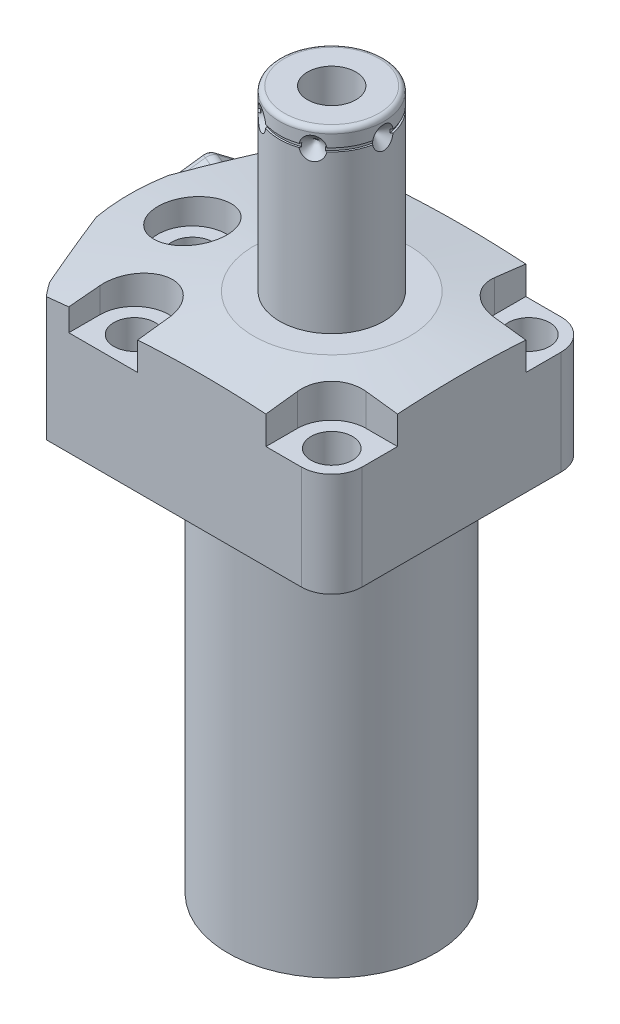
from build123d import *

# Parameters (mm, degrees)
CUT_EXTRUDE1_DEPTH       = 32.9946
CUT_EXTRUDE2_DEPTH       = 30.1498
CUT_EXTRUDE3_DEPTH       = 32.9946
FILLET1_R                = 6.477
CUT_EXTRUDE4_DEPTH       = 8.001
SKETCH11_R               = 2.7432
EXTRUDE1_DEPTH           = 2.9972
CUT_EXTRUDE5_DEPTH       = 1.27
CHAMFER1_SIZE            = 0.254
CHAMFER1_OF_MIRROR2_SIZE = 0.254
SKETCH16_R               = 1
SKETCH19_R               = 8.5
EXTRUDE3_DEPTH           = 1
SKETCH22_W               = 0.381
SKETCH22_H               = 0.762
HOLE1_AT_2_COUNT         = 2
HOLE1_AT_2_PITCH         = 54.877785999
HOLE1_AT_3_COUNT         = 2
HOLE1_AT_3_PITCH         = 54.877785999
HOLE1_AT_4_COUNT         = 2
HOLE1_AT_4_PITCH         = 22.73112685
HOLE1_AT_5_COUNT         = 2
HOLE1_AT_5_PITCH         = 22.73112685
SKETCH25_R               = 11.3665
CUT_EXTRUDE7_DEPTH       = 1.524
EXTRUDE4_DEPTH           = 6.87
FILLET2_R                = 2
CIRPATTERN1_COUNT        = 6


with BuildPart() as part:
    # S2D0002 → Revolve1 (revolve)
    with BuildSketch(Plane.XY, mode=Mode.PRIVATE) as revolve1_sk:
        Polygon((-43.18, 0), (-43.18, 30.1498), (0, 30.1498), (0, -80.9752), (-22.098, -80.9752), (-22.098, 0), align=None)
    revolve(revolve1_sk.sketch.rotate(Axis((0, -3.4925, 0), (0, 1, 0)), 270), axis=Axis((0, -3.4925, 0), (0, 1, 0)))  # turned: the seam where the file's is

    # S2D0001 → Cut-Extrude1 (cut)
    with BuildSketch(Plane.XZ):
        with BuildLine():
            Line((-33.136049915, -27.686), (33.136049915, -27.686))
            ThreePointArc((33.136049915, -27.686), (0, -43.18), (-33.136049915, -27.686))
        make_face()
        with BuildLine():
            Line((33.136049915, 27.686), (-33.136049915, 27.686))
            ThreePointArc((-33.136049915, 27.686), (0, 43.18), (33.136049915, 27.686))
        make_face()
    extrude(amount=-CUT_EXTRUDE1_DEPTH, mode=Mode.SUBTRACT)

    # Sketch3 → Cut-Extrude2 (cut)
    with BuildSketch(Plane(origin=(0, 30.1498, 0), x_dir=(-1, 0, 0), z_dir=(0, -1, 0))):
        with BuildLine():
            Line((21.331674578, 58.746997027), (45.665477495, 0))
            Line((45.665477495, 0), (21.331674578, -58.746997027))
            ThreePointArc((21.331674578, -58.746997027), (62.5, 0), (21.331674578, 58.746997027))
        make_face()
    extrude(amount=CUT_EXTRUDE2_DEPTH, mode=Mode.SUBTRACT)

    # Sketch4 → Cut-Extrude3 (cut)
    with BuildSketch(Plane.XZ):
        with BuildLine():
            Line((27.686, -33.136049915), (27.686, 33.136049915))
            ThreePointArc((27.686, 33.136049915), (43.18, 0), (27.686, -33.136049915))
        make_face()
    extrude(amount=-CUT_EXTRUDE3_DEPTH, mode=Mode.SUBTRACT)

    # Fillet1
    fillet1_edges = [part.edges().sort_by_distance(p)[0] for p in [
        (27.686, 15.0749, 27.686),
        (27.686, 15.0749, -27.686),
    ]]
    fillet(fillet1_edges, radius=FILLET1_R)

    # Sketch5 → Cut-Extrude4 (cut)
    with BuildSketch(Plane(origin=(0, 30.1498, 0), x_dir=(-1, 0, 0), z_dir=(0, 1, 0))):
        with BuildLine():
            Line((-27.686, -13.6652), (-27.686, -27.686))
            Line((-27.686, -27.686), (-13.6652, -27.686))
            Line((-13.6652, -27.686), (-13.6652, -21.0058))
            ThreePointArc((-13.6652, -21.0058), (-15.815211962, -15.815211962), (-21.0058, -13.6652))
            Line((-21.0058, -13.6652), (-27.686, -13.6652))
        make_face()
        with BuildLine():
            Line((-13.6652, 21.0058), (-13.6652, 27.686))
            Line((-13.6652, 27.686), (-27.686, 27.686))
            Line((-27.686, 27.686), (-27.686, 13.6652))
            Line((-27.686, 13.6652), (-21.0058, 13.6652))
            ThreePointArc((-21.0058, 13.6652), (-15.815211962, 15.815211962), (-13.6652, 21.0058))
        make_face()
        with BuildLine():
            Line((13.6652, 27.686), (28.3464, 27.686))
            Line((28.3464, 27.686), (28.3464, 21.0058))
            ThreePointArc((28.3464, 21.0058), (21.0058, 13.6652), (13.6652, 21.0058))
            Line((13.6652, 21.0058), (13.6652, 27.686))
        make_face()
        with BuildLine():
            Line((13.6652, -27.686), (13.6652, -21.0058))
            ThreePointArc((13.6652, -21.0058), (21.0058, -13.6652), (28.3464, -21.0058))
            Line((28.3464, -21.0058), (28.3464, -27.686))
            Line((28.3464, -27.686), (13.6652, -27.686))
        make_face()
    extrude(amount=-CUT_EXTRUDE4_DEPTH, mode=Mode.SUBTRACT)

    # S2D0003 → Cut-Revolve1 (revolve, cut)
    with BuildSketch(Plane.XY, mode=Mode.PRIVATE) as cut_revolve1_sk:
        Polygon((-16.637, 30.1498), (-86.637, 20.311941571), (-86.637, 30.1498), align=None)
    revolve(cut_revolve1_sk.sketch.rotate(Axis((0, 12.958028823, 0), (0, 1, 0)), 270), axis=Axis((0, 12.958028823, 0), (0, 1, 0)), mode=Mode.SUBTRACT)  # turned: the seam where the file's is

    # Sketch7 → Cut-Revolve2 (revolve, cut)
    with BuildSketch(Plane.XZ.offset(-14.5034)):
        Polygon((-41.173297543, -10.181347778), (-42.857104646, -6.116277835), (-43.091770047, -6.213479427), (-38.977923149, -16.145184401), (-25.648928357, -10.624133986), (-27.923445606, -5.132963597), (-40.549917486, -10.363019494), (-41.04563442, -10.157686817), align=None)
    cut_revolve2 = revolve(axis=Axis((0, 14.5034, 0), (0.923879533, 0, 0.382683432)), mode=Mode.SUBTRACT)

    # Sketch9 → Cut-Revolve4 (revolve, cut)
    with BuildSketch(Plane.XY.offset(-11.8364), mode=Mode.PRIVATE) as cut_revolve4_sk:
        Polygon((-31.8262, 1.5), (-33.575, 1.5), (-33.575, 0), (-28.575, 0), (-28.575, 12.0664), (-29.8196, 12.0664), (-29.8196, 4.4972), (-31.8262, 4.4972), align=None)
    cut_revolve4 = revolve(cut_revolve4_sk.sketch.rotate(Axis((-28.575, -17.893386483, -11.8364), (0, 1, 0)), 180), axis=Axis((-28.575, -17.893386483, -11.8364), (0, 1, 0)), mode=Mode.SUBTRACT)  # turned: the seam where the file's is

    # Sketch11 → Extrude1 (add)
    with BuildSketch(Plane.XZ.offset(-4.4972)):
        with Locations(Location((-28.575, -11.8364, 0), (0, 0, 270))):  # turned: the seam where the file's is
            Circle(SKETCH11_R)
    extrude1 = extrude(amount=EXTRUDE1_DEPTH)

    # Sketch12 → Cut-Extrude5 (cut)
    with BuildSketch(Plane.XZ.offset(-1.5)):
        Polygon((-27.3304, -12.554970145), (-27.3304, -11.117829855), (-28.575, -10.39925971), (-29.8196, -11.117829855), (-29.8196, -12.554970145), (-28.575, -13.27354029), align=None)
    cut_extrude5 = extrude(amount=-CUT_EXTRUDE5_DEPTH, mode=Mode.SUBTRACT)

    # Chamfer1
    chamfer1_edges = [part.edges().sort_by_distance(p)[0] for p in [
        (-28.575, 1.5, -9.0932),
    ]]
    chamfer(chamfer1_edges, length=CHAMFER1_SIZE)

    # Mirror2: Cut-Revolve2, Cut-Revolve4, Extrude1, Cut-Extrude5 across plane
    add(cut_revolve2.mirror(Plane.XY), mode=Mode.SUBTRACT)
    add(cut_revolve4.mirror(Plane.XY), mode=Mode.SUBTRACT)
    add(extrude1.mirror(Plane.XY))
    add(cut_extrude5.mirror(Plane.XY), mode=Mode.SUBTRACT)

    # Chamfer1 of Mirror2
    chamfer1_of_mirror2_edges = [part.edges().sort_by_distance(p)[0] for p in [
        (-28.575, 1.5, 9.0932),
    ]]
    chamfer(chamfer1_of_mirror2_edges, length=CHAMFER1_OF_MIRROR2_SIZE)

    # Sketch17 → Revolve4 (revolve)
    with BuildSketch(Plane(origin=(0, 0, 0), x_dir=(0, 0, -1), z_dir=(1, 0, 0)), mode=Mode.PRIVATE) as revolve4_sk:
        with BuildLine():
            Line((0, 30.1498), (-11.1125, 30.1498))
            Line((-11.1125, 30.1498), (-11.1125, 67.018))
            ThreePointArc((-11.1125, 67.018), (-10.81492049, 67.73642049), (-10.0965, 68.034))
            Line((-10.0965, 68.034), (0, 68.034))
            Line((0, 68.034), (0, 30.1498))
        make_face()
    revolve(revolve4_sk.sketch.rotate(Axis((0, 24.99613, 0), (0, 1, 0)), 180), axis=Axis((0, 24.99613, 0), (0, 1, 0)))  # turned: the seam where the file's is

    # Sketch18 → Cut-Revolve7 (revolve, cut)
    with BuildSketch(Plane.XY, mode=Mode.PRIVATE) as cut_revolve7_sk:
        Polygon((5.1562, 68.034), (5.1562, 51.016), (0, 47.917842476), (0, 68.034), align=None)
    revolve(cut_revolve7_sk.sketch.rotate(Axis((0, -20.475979697, 0), (0, 1, 0)), 90), axis=Axis((0, -20.475979697, 0), (0, 1, 0)), mode=Mode.SUBTRACT)  # turned: the seam where the file's is

    # Sketch19 → Extrude3 (add)
    with BuildSketch(Plane(origin=(-52.256800889, 0, 16.576596317), x_dir=(-0.382683432, 0, 0.923879533), z_dir=(-0.923879533, 0, -0.382683432))):
        with Locations((-35.312589984, 14.5034)):
            Circle(SKETCH19_R)
    extrude(amount=EXTRUDE3_DEPTH)

    # Sketch20 → Cut-Revolve8 (revolve, cut)
    with BuildSketch(Plane.XY, mode=Mode.PRIVATE) as cut_revolve8_sk:
        Polygon((-11.1125, 61.6586), (-11.1125, 64.0716), (-8.6995, 64.0716), align=None)
    cut_revolve8 = revolve(cut_revolve8_sk.sketch.rotate(Axis((0, 64.0716, 0), (1, 0, 0)), 270), axis=Axis((0, 64.0716, 0), (1, 0, 0)), mode=Mode.SUBTRACT)  # turned: the seam where the file's is

    # Sketch22 → Cut-Revolve6 (revolve, cut)
    with BuildSketch(Plane(origin=(0, 0, 0), x_dir=(0, 0, -1), z_dir=(1, 0, 0))):
        with Locations((10.922, 64.072)):
            Rectangle(SKETCH22_W, SKETCH22_H)
    revolve(axis=Axis((0, 41.8979, 0), (0, 1, 0)), mode=Mode.SUBTRACT)

    # Sketch23 → Hole1 (revolve, cut)
    with BuildSketch(Plane(origin=(-29.6926, 30.1498, 0), x_dir=(0, 0, 1), z_dir=(1, 0, 0))):
        Polygon((0, 0), (0, 30.1498), (4.4196, 30.1498), (4.4196, 8.001), (7.3406, 8.001), (7.3406, 0), align=None)
    hole1 = revolve(axis=Axis((-29.6926, -79.8502, 0), (0, 1, 0)), mode=Mode.SUBTRACT)

    # Hole1 at 2: Hole1 ×2
    with Locations(*[Vector(0.923841935, 0, 0.382774188) * (i * HOLE1_AT_2_PITCH) for i in range(1, HOLE1_AT_2_COUNT)]):
        add(hole1, mode=Mode.SUBTRACT)

    # Hole1 at 3: Hole1 ×2
    with Locations(*[Vector(0.923841935, 0, -0.382774188) * (i * HOLE1_AT_3_PITCH) for i in range(1, HOLE1_AT_3_COUNT)]):
        add(hole1, mode=Mode.SUBTRACT)

    # Hole1 at 4: Hole1 ×2
    with Locations(*[Vector(0.382154394, 0, 0.92409849) * (i * HOLE1_AT_4_PITCH) for i in range(1, HOLE1_AT_4_COUNT)]):
        add(hole1, mode=Mode.SUBTRACT)

    # Hole1 at 5: Hole1 ×2
    with Locations(*[Vector(0.382154394, 0, -0.92409849) * (i * HOLE1_AT_5_PITCH) for i in range(1, HOLE1_AT_5_COUNT)]):
        add(hole1, mode=Mode.SUBTRACT)

    # Sketch25 → Cut-Extrude7 (cut)
    with BuildSketch(Plane.XZ.offset(80.9752)):
        with Locations(Location((0, 0, 0), (0, 0, 270))):  # turned: the seam where the file's is
            Circle(SKETCH25_R)
    extrude(amount=-CUT_EXTRUDE7_DEPTH, mode=Mode.SUBTRACT)

    # Sketch27 → Extrude4 (add)
    with BuildSketch(Plane(origin=(-39.66713728, 0, -16.430666242), x_dir=(-0.382683432, 0, 0.923879533), z_dir=(-0.923879533, 0, -0.382683432))):
        Polygon((8.399828748, 19.580427707), (-0.196920596, 24.316378937), (-8.596749344, 19.239351229), (-8.399828748, 9.426372293), (0.196920596, 4.690421063), (8.596749344, 9.767448771), align=None)
    extrude(amount=EXTRUDE4_DEPTH)

    # Fillet2
    fillet2_edges = [part.edges().sort_by_distance(p)[0] for p in [
        (-46.130497021, 9.767448771, -9.802823067),
        (-46.055138771, 19.580427707, -9.984753975),
        (-42.765305225, 24.316378937, -17.927114741),
        (-39.550829928, 19.239351229, -25.687544597),
        (-39.626188178, 9.426372293, -25.505613689),
        (-42.916021724, 4.690421063, -17.563252924),
        (-49.26634409, 14.673938239, -11.208306111),
        (-47.583748192, 21.948403322, -15.270451948),
        (-44.331593771, 21.777865083, -23.121847259),
        (-42.762035247, 14.332861761, -26.911096733),
        (-44.444631145, 7.058396678, -22.848950896),
        (-47.696785567, 7.228934917, -14.997555585),
    ]]
    fillet(fillet2_edges, radius=FILLET2_R)

    # CirPattern1: Cut-Revolve8 ×6 about axis
    cirpattern1_axis = Axis((0, -3.4925, 0), (0, 1, 0))
    for i in range(1, CIRPATTERN1_COUNT):
        add(cut_revolve8.rotate(cirpattern1_axis, i * 360 / CIRPATTERN1_COUNT), mode=Mode.SUBTRACT)


with BuildPart() as body_2:
    # Sketch16 → Revolve3 (revolve)
    with BuildSketch(Plane(origin=(-18.1864, 0, -11.8364), x_dir=(-1, 0, 0), z_dir=(0, 0, -1)), mode=Mode.PRIVATE) as revolve3_sk:
        with Locations((14.3886, 0.5)):
            Circle(SKETCH16_R)
    revolve(revolve3_sk.sketch.rotate(Axis((-28.575, -0.4101, -11.8364), (0, 1, 0)), 180), axis=Axis((-28.575, -0.4101, -11.8364), (0, 1, 0)))  # turned: the seam where the file's is


with BuildPart() as body_3:
    # Mirror3: mirrored copy
    add(body_2.part.mirror(Plane.XY))


solid = Compound([part.part, body_2.part, body_3.part])
